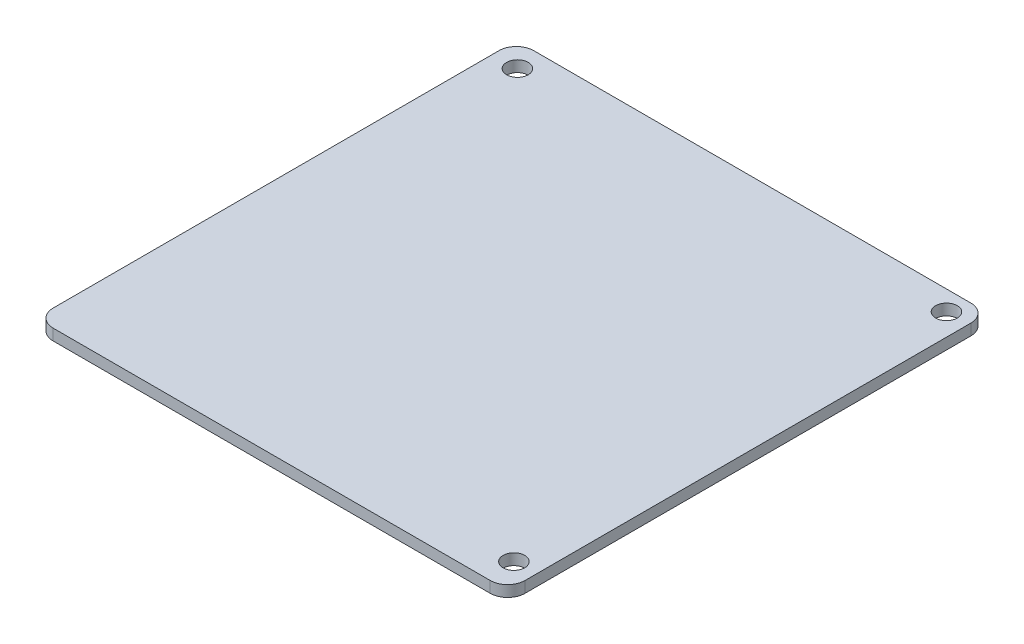
from build123d import *

# Parameters (mm, degrees)
SKETCH1_W                  = 67.748
SKETCH1_H                  = 69
BOSS_EXTRUDE1_DEPTH        = 1.6
M2_5_CLEARANCE_HOLE2_D     = 3.1
M2_5_CLEARANCE_HOLE2_DEPTH = 50.8
M2_5_CLEARANCE_HOLE2_TIP   = 0.931333959
FILLET1_R                  = 2.5


with BuildPart() as part:
    # Sketch1 → Boss-Extrude1 (new body)
    with BuildSketch(Plane(origin=(0, 0, 0), x_dir=(1, 0, 0), z_dir=(0, 1, 0))):
        Rectangle(SKETCH1_W, SKETCH1_H)
    extrude(amount=BOSS_EXTRUDE1_DEPTH)

    # M2.5 Clearance Hole2
    with Locations(Plane(origin=(0, 1.6, 0), x_dir=(1, 0, 0), z_dir=(0, 1, 0))):
        with Locations((30.724, -30.453), (-30.323, 31.1), (30.727, 31.65)):
            Hole(M2_5_CLEARANCE_HOLE2_D / 2, depth=M2_5_CLEARANCE_HOLE2_DEPTH)
            with Locations((0, 0, -(M2_5_CLEARANCE_HOLE2_DEPTH + M2_5_CLEARANCE_HOLE2_TIP / 2))):  # 118° drill point
                Cone(0, M2_5_CLEARANCE_HOLE2_D / 2, M2_5_CLEARANCE_HOLE2_TIP, mode=Mode.SUBTRACT)

    # Fillet1
    fillet1_edges = [part.edges().sort_by_distance(p)[0] for p in [
        (33.874, 0.8, 34.5),
        (-33.874, 0.8, 34.5),
        (-33.874, 0.8, -34.5),
        (33.874, 0.8, -34.5),
    ]]
    fillet(fillet1_edges, radius=FILLET1_R)


solid = part.part
